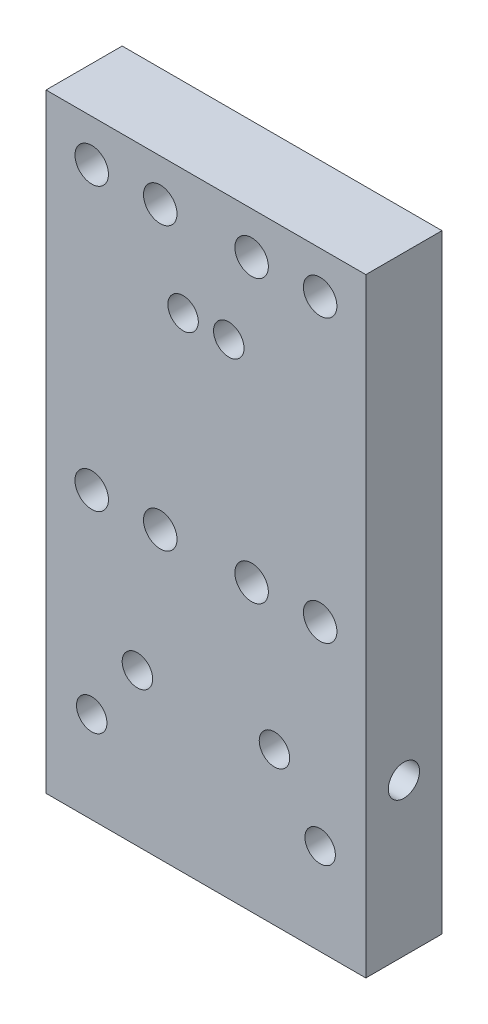
from build123d import *

# Parameters (mm, degrees)
SKETCH1_W                = 21
SKETCH1_H                = 5
BOSS_EXTRUDE1_DEPTH      = 40
M2_5_TAPPED_HOLE1_D      = 2.05
M2_5_TAPPED_HOLE1_DEPTH  = 10
M2_5_TAPPED_HOLE1_TIP    = 0.615882135
M2_CLEARANCE_HOLE1_D     = 2.2
F_2_0_2_DIAMETER_HOLE2_D = 2
F_2_0_2_DIAMETER_HOLE3_D = 2


with BuildPart() as part:
    # Sketch1 → Boss-Extrude1 (new body)
    with BuildSketch(Plane(origin=(0, 0, 0), x_dir=(1, 0, 0), z_dir=(0, 1, 0))):
        Rectangle(SKETCH1_W, SKETCH1_H)
    extrude(amount=BOSS_EXTRUDE1_DEPTH)

    # M2.5 Tapped Hole1
    with Locations(Plane(origin=(0, 0, 0), x_dir=(-1, 0, 0), z_dir=(0, -1, 0))):
        with Locations((7.5, 0), (-7.5, 0)):
            Hole(M2_5_TAPPED_HOLE1_D / 2, depth=M2_5_TAPPED_HOLE1_DEPTH)
            with Locations((0, 0, -(M2_5_TAPPED_HOLE1_DEPTH + M2_5_TAPPED_HOLE1_TIP / 2))):  # 118° drill point
                Cone(0, M2_5_TAPPED_HOLE1_D / 2, M2_5_TAPPED_HOLE1_TIP, mode=Mode.SUBTRACT)

    # M2 Clearance Hole1 (through all)
    with Locations(Plane(origin=(0, 0, -2.5), x_dir=(-1, 0, 0), z_dir=(0, 0, -1))):
        with Locations((-7.5, 37.25), (7.5, 37.25), (-7.5, 18.75), (7.5, 18.75), (-3, 37.25), (3, 37.25), (-3, 18.75), (3, 18.75)):
            Hole(M2_CLEARANCE_HOLE1_D / 2)

    # Ø2.0 (2) Diameter Hole2 (through all)
    with Locations(Plane(origin=(0, 0, -2.5), x_dir=(-1, 0, 0), z_dir=(0, 0, -1))):
        with Locations((1.5, 31.81), (-1.5, 31.81)):
            Hole(F_2_0_2_DIAMETER_HOLE2_D / 2)

    # Sketch11 → M2.5 Tapped Hole2 (revolve, cut)
    with BuildSketch(Plane(origin=(10.5, 10, 0), x_dir=(0, 0, -1), z_dir=(0, 1, 0))):
        Polygon((0, 0), (0, 6.965882135), (1.025, 6.35), (1.025, 0), align=None)
    m2_5_tapped_hole2 = revolve(axis=Axis((16.85, 10, 0), (-1, 0, 0)), mode=Mode.SUBTRACT)

    # Mirror1: M2.5 Tapped Hole2 across plane
    add(m2_5_tapped_hole2.mirror(Plane(origin=(0, 0, 0), x_dir=(0, 0, 1), z_dir=(1, 0, 0))), mode=Mode.SUBTRACT)

    # Ø2.0 (2) Diameter Hole3 (through all)
    with Locations(Plane(origin=(0, 0, -2.5), x_dir=(-1, 0, 0), z_dir=(0, 0, -1))):
        with Locations((-4.5, 10), (4.5, 10), (-7.5, 6), (7.5, 6)):
            Hole(F_2_0_2_DIAMETER_HOLE3_D / 2)


solid = part.part
